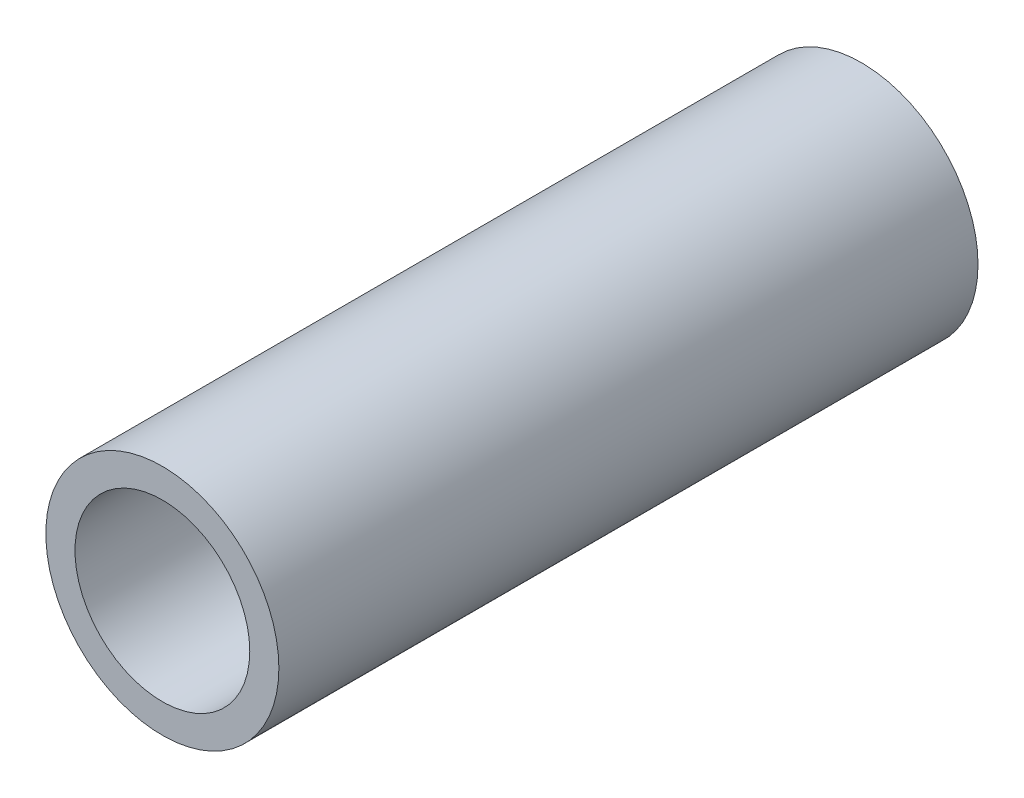
from build123d import *

# Parameters (mm, degrees)
SKETCH1_R           = 4.233333333
SKETCH1_R_2         = 3.175
BOSS_EXTRUDE1_DEPTH = 25.4


with BuildPart() as part:
    # Sketch1 → Boss-Extrude1 (new body)
    with BuildSketch(Plane.XY):
        Circle(SKETCH1_R)
        Circle(SKETCH1_R_2, mode=Mode.SUBTRACT)
    extrude(amount=BOSS_EXTRUDE1_DEPTH)


solid = part.part
